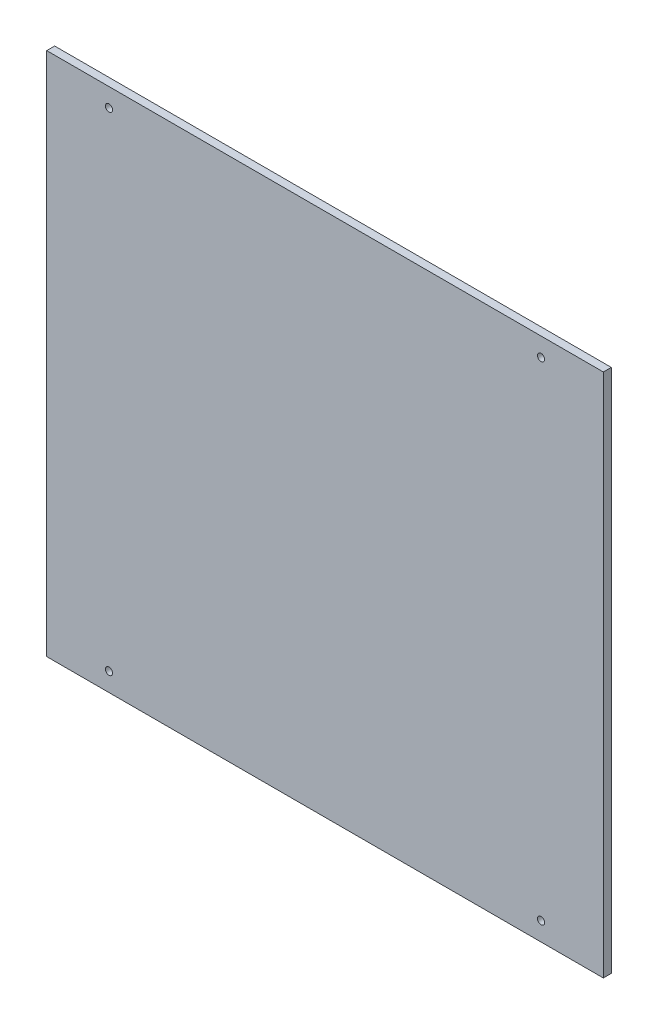
from build123d import *

# Parameters (mm, degrees)
ESQUISSE1_W            = 210
ESQUISSE1_H            = 198
BOSS_EXTRU_1_DEPTH     = 3
D_GAGEMENT_M2_51_D     = 2.7
D_GAGEMENT_M2_51_DEPTH = 3


with BuildPart() as part:
    # Esquisse1 → Boss.-Extru.1 (new body)
    with BuildSketch(Plane.XY):
        Rectangle(ESQUISSE1_W, ESQUISSE1_H)
    extrude(amount=BOSS_EXTRU_1_DEPTH)

    # Dégagement M2.51
    with Locations(Plane.XY.offset(3)):
        with Locations((-81.5, -92), (-81.5, 92), (81.5, 92), (81.5, -92)):
            Hole(D_GAGEMENT_M2_51_D / 2, depth=D_GAGEMENT_M2_51_DEPTH)


solid = part.part
